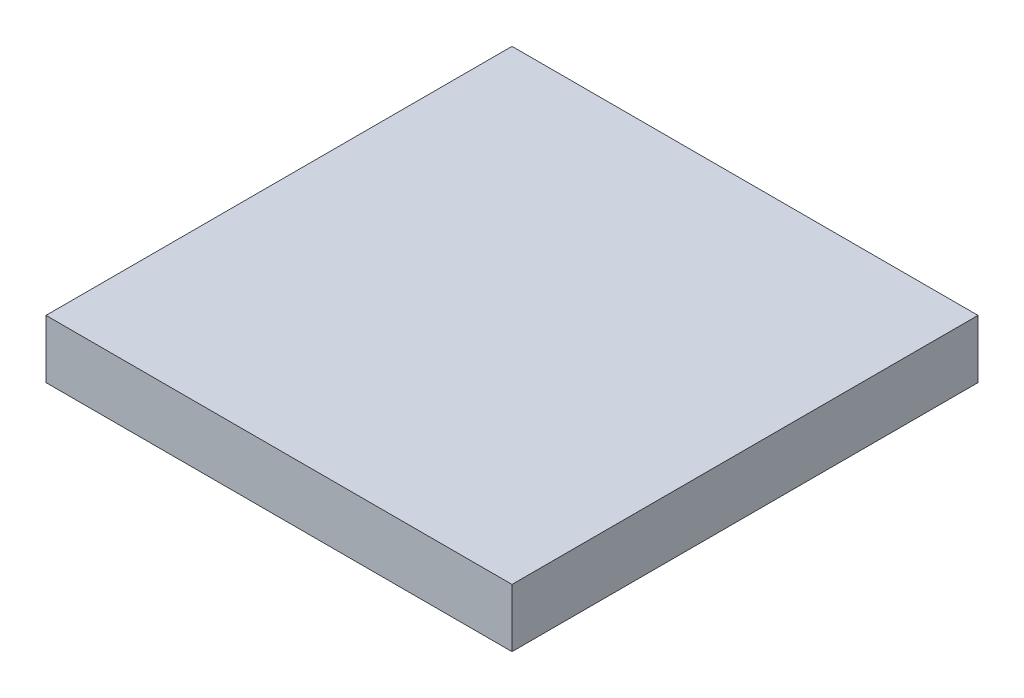
from build123d import *

# Parameters (mm, degrees)
SKETCH1_W      = 20.32
SKETCH1_H      = 20.32
EXTRUDE1_DEPTH = 2.54


with BuildPart() as part:
    # Sketch1 → Extrude1 (new body)
    with BuildSketch(Plane(origin=(0, 0, 0), x_dir=(1, 0, 0), z_dir=(0, 1, 0))):
        Rectangle(SKETCH1_W, SKETCH1_H)
    extrude(amount=EXTRUDE1_DEPTH)


solid = part.part
